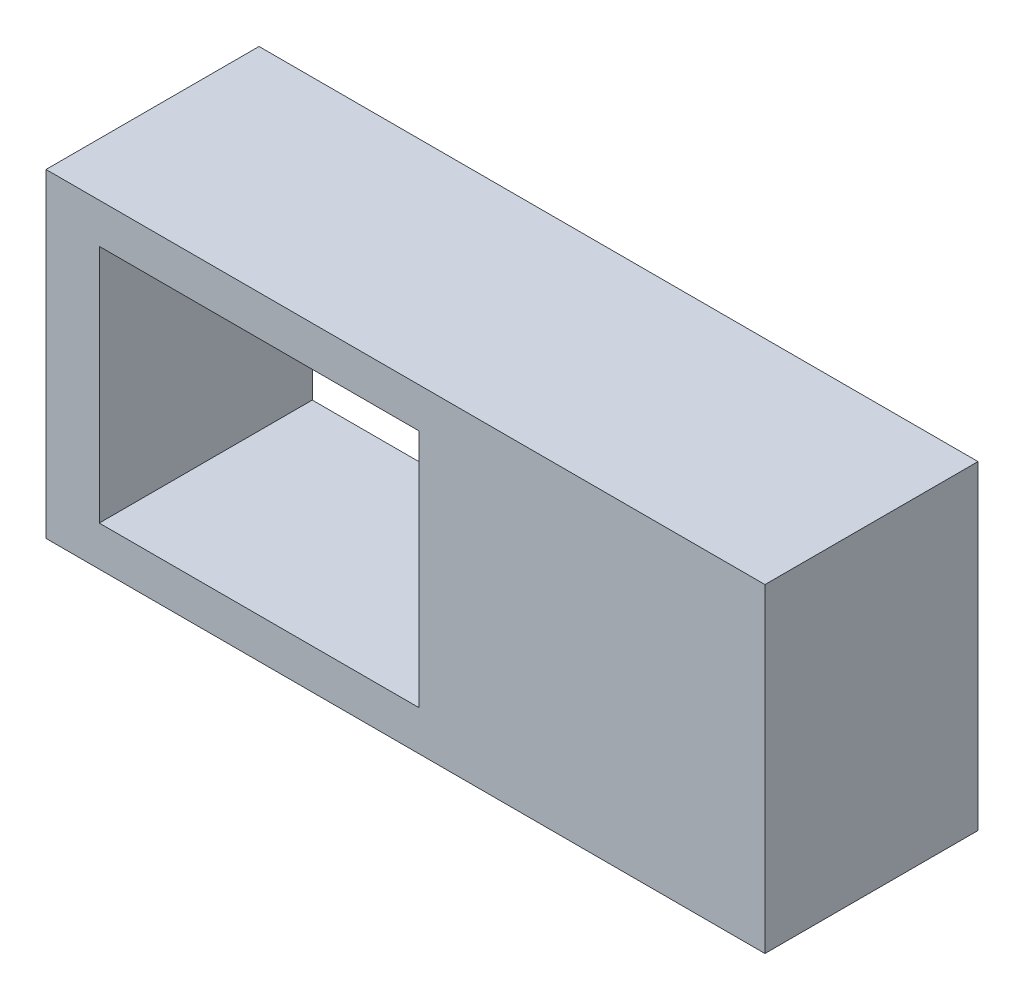
from build123d import *

# Parameters (mm, degrees)
SKETCH_1_W      = 27
SKETCH_1_H      = 12
SKETCH_1_W_2    = 23
SKETCH_1_H_2    = 9
EXTRUDE_1_DEPTH = 8
SKETCH_2_W      = 11
SKETCH_2_H      = 9
EXTRUDE_2_DEPTH = 2
SKETCH_3_R      = 2.75
SKETCH_3_R_2    = 1.55
EXTRUDE_3_DEPTH = 5


with BuildPart() as part:
    # 草图1 → 凸台-拉伸1 (new body)
    with BuildSketch(Plane.XY):
        Rectangle(SKETCH_1_W, SKETCH_1_H)
        Rectangle(SKETCH_1_W_2, SKETCH_1_H_2, mode=Mode.SUBTRACT)
    extrude(amount=EXTRUDE_1_DEPTH)

    # 草图2 → 凸台-拉伸2 (add)
    with BuildSketch(Plane.XY.offset(8)):
        with Locations((6, 0)):
            Rectangle(SKETCH_2_W, SKETCH_2_H)
    extrude(amount=-EXTRUDE_2_DEPTH)

    # 草图3 → 凸台-拉伸3 (add)
    with BuildSketch(Plane(origin=(0, 0, 6), x_dir=(-1, 0, 0), z_dir=(0, 0, -1))):
        with Locations((-6.35, 0)):
            Circle(SKETCH_3_R)
        with Locations((-6.35, 0)):
            Circle(SKETCH_3_R_2, mode=Mode.SUBTRACT)
    extrude(amount=EXTRUDE_3_DEPTH)


solid = part.part
